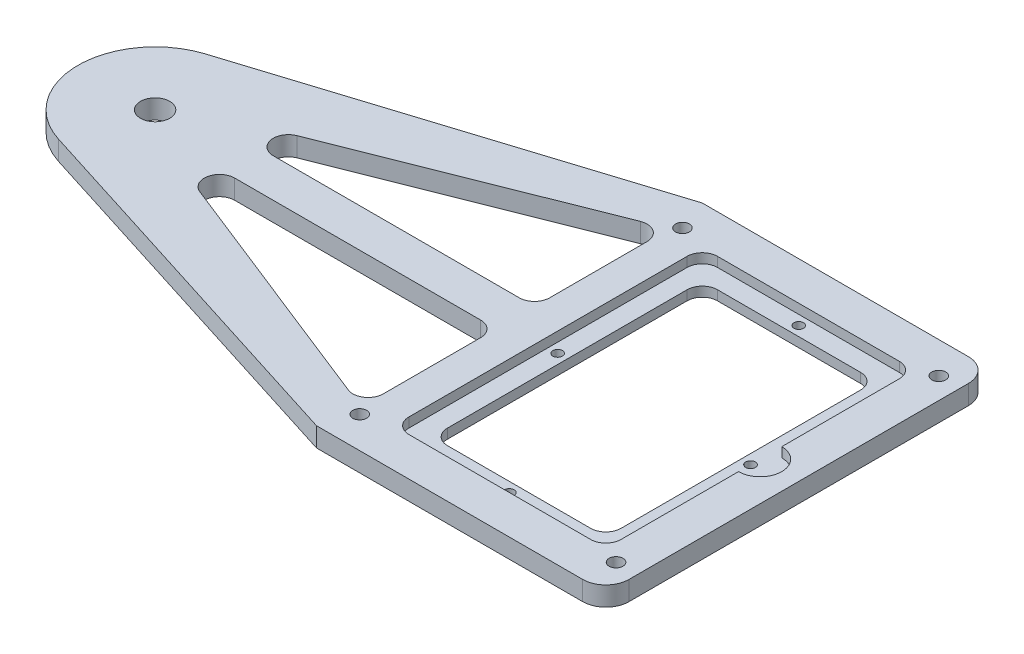
from build123d import *

# Parameters (mm, degrees)
SKETCH1_W           = 95.25
SKETCH1_H           = 127
BOSS_EXTRUDE1_DEPTH = 6.35
BOSS_EXTRUDE3_DEPTH = 6.35
SKETCH5_R           = 4.826
CUT_EXTRUDE1_DEPTH  = 7.35
CUT_EXTRUDE2_DEPTH  = 7.35
FILLET9_R           = 5
SKETCH7_R           = 5.453804141
BOSS_EXTRUDE4_DEPTH = 6.35
SKETCH8_W           = 69.85
SKETCH8_H           = 101.6
CUT_EXTRUDE3_DEPTH  = 3.175
SKETCH9_W           = 57.15
SKETCH9_H           = 88.9
CUT_EXTRUDE4_DEPTH  = 4.175
SKETCH11_R          = 1.5875
CUT_EXTRUDE6_DEPTH  = 4.175
CUT_EXTRUDE7_DEPTH  = 3.175
FILLET10_R          = 5
FILLET11_R          = 5
FILLET12_R          = 7.62
SKETCH13_R          = 2.2812375
CUT_EXTRUDE8_DEPTH  = 7.35


with BuildPart() as part:
    # Sketch1 → Boss-Extrude1 (new body)
    with BuildSketch(Plane(origin=(0, 0, 0), x_dir=(1, 0, 0), z_dir=(0, 1, 0))):
        Rectangle(SKETCH1_W, SKETCH1_H)
    extrude(amount=BOSS_EXTRUDE1_DEPTH)

    # Sketch4 → Boss-Extrude3 (add)
    with BuildSketch(Plane(origin=(0, 6.35, 0), x_dir=(1, 0, 0), z_dir=(0, 1, 0))):
        with BuildLine():
            Line((-47.625, 63.5), (-171.916018217, 24.219268021))
            ThreePointArc((-171.916018217, 24.219268021), (-189.6618, 0), (-171.916018217, -24.219268021))
            Line((-171.916018217, -24.219268021), (-47.625, -63.5))
            Line((-47.625, -63.5), (-47.625, 63.5))
        make_face()
    extrude(amount=-BOSS_EXTRUDE3_DEPTH)

    # Sketch5 → Cut-Extrude1 (cut, through all)
    with BuildSketch(Plane(origin=(0, 6.35, 0), x_dir=(1, 0, 0), z_dir=(0, 1, 0))):
        with Locations((-164.2618, 0)):
            Circle(SKETCH5_R)
        with Locations((-8.6868, 0)):
            Circle(SKETCH5_R)
    extrude(amount=-CUT_EXTRUDE1_DEPTH, mode=Mode.SUBTRACT)

    # Sketch6 → Cut-Extrude2 (cut, through all)
    with BuildSketch(Plane(origin=(0, 6.35, 0), x_dir=(1, 0, 0), z_dir=(0, 1, 0))):
        Polygon((-45.72, 50.782905742), (-157.9118, 6.35), (-45.72, 6.35), align=None)
        Polygon((-45.72, -6.35), (-45.72, -50.782905742), (-157.9118, -6.35), align=None)
    extrude(amount=-CUT_EXTRUDE2_DEPTH, mode=Mode.SUBTRACT)

    # Fillet9
    fillet9_edges = [part.edges().sort_by_distance(p)[0] for p in [
        (-45.72, 3.175, -50.782905742),
        (-45.72, 3.175, -6.35),
        (-157.9118, 3.175, -6.35),
        (-157.9118, 3.175, 6.35),
        (-45.72, 3.175, 6.35),
        (-45.72, 3.175, 50.782905742),
    ]]
    fillet(fillet9_edges, radius=FILLET9_R)

    # Sketch7 → Boss-Extrude4 (add)
    with BuildSketch(Plane(origin=(0, 6.35, 0), x_dir=(1, 0, 0), z_dir=(0, 1, 0))):
        with Locations((-8.6868, 0)):
            Circle(SKETCH7_R)
    extrude(amount=-BOSS_EXTRUDE4_DEPTH)

    # Sketch8 → Cut-Extrude3 (cut)
    with BuildSketch(Plane(origin=(0, 6.35, 0), x_dir=(1, 0, 0), z_dir=(0, 1, 0))):
        Rectangle(SKETCH8_W, SKETCH8_H)
    extrude(amount=-CUT_EXTRUDE3_DEPTH, mode=Mode.SUBTRACT)

    # Sketch9 → Cut-Extrude4 (cut, through all)
    with BuildSketch(Plane(origin=(0, 3.175, 0), x_dir=(1, 0, 0), z_dir=(0, 1, 0))):
        Rectangle(SKETCH9_W, SKETCH9_H)
    extrude(amount=-CUT_EXTRUDE4_DEPTH, mode=Mode.SUBTRACT)

    # Sketch11 → Cut-Extrude6 (cut, through all)
    with BuildSketch(Plane(origin=(0, 3.175, 0), x_dir=(1, 0, 0), z_dir=(0, 1, 0))):
        with Locations((-31.75, 0)):
            Circle(SKETCH11_R)
        with Locations((31.75, 0)):
            Circle(SKETCH11_R)
        with Locations((0, 47.625)):
            Circle(SKETCH11_R)
        with Locations((0, -47.625)):
            Circle(SKETCH11_R)
    extrude(amount=-CUT_EXTRUDE6_DEPTH, mode=Mode.SUBTRACT)

    # Sketch12 → Cut-Extrude7 (cut)
    with BuildSketch(Plane(origin=(0, 6.35, 0), x_dir=(1, 0, 0), z_dir=(0, 1, 0))):
        with BuildLine():
            Line((34.925, 7.112), (34.925, -7.112))
            ThreePointArc((34.925, -7.112), (42.037, 0), (34.925, 7.112))
        make_face()
    extrude(amount=-CUT_EXTRUDE7_DEPTH, mode=Mode.SUBTRACT)

    # Fillet10
    fillet10_edges = [part.edges().sort_by_distance(p)[0] for p in [
        (-34.925, 4.7625, -50.8),
        (34.925, 4.7625, -50.8),
        (34.925, 4.7625, 50.8),
        (-34.925, 4.7625, 50.8),
    ]]
    fillet(fillet10_edges, radius=FILLET10_R)

    # Fillet11
    fillet11_edges = [part.edges().sort_by_distance(p)[0] for p in [
        (-28.575, 1.5875, 44.45),
        (-28.575, 1.5875, -44.45),
        (28.575, 1.5875, -44.45),
        (28.575, 1.5875, 44.45),
    ]]
    fillet(fillet11_edges, radius=FILLET11_R)

    # Fillet12
    fillet12_edges = [part.edges().sort_by_distance(p)[0] for p in [
        (47.625, 3.175, 63.5),
        (47.625, 3.175, -63.5),
    ]]
    fillet(fillet12_edges, radius=FILLET12_R)

    # Sketch13 → Cut-Extrude8 (cut, through all)
    with BuildSketch(Plane(origin=(0, 6.35, 0), x_dir=(1, 0, 0), z_dir=(0, 1, 0))):
        with Locations((-43.777254611, 53.125383493)):
            Circle(SKETCH13_R)
        with Locations((-43.777254611, -53.125383493)):
            Circle(SKETCH13_R)
        with Locations((40.602254611, -53.125383493)):
            Circle(SKETCH13_R)
        with Locations((40.602254611, 53.125383493)):
            Circle(SKETCH13_R)
    extrude(amount=-CUT_EXTRUDE8_DEPTH, mode=Mode.SUBTRACT)


solid = part.part
